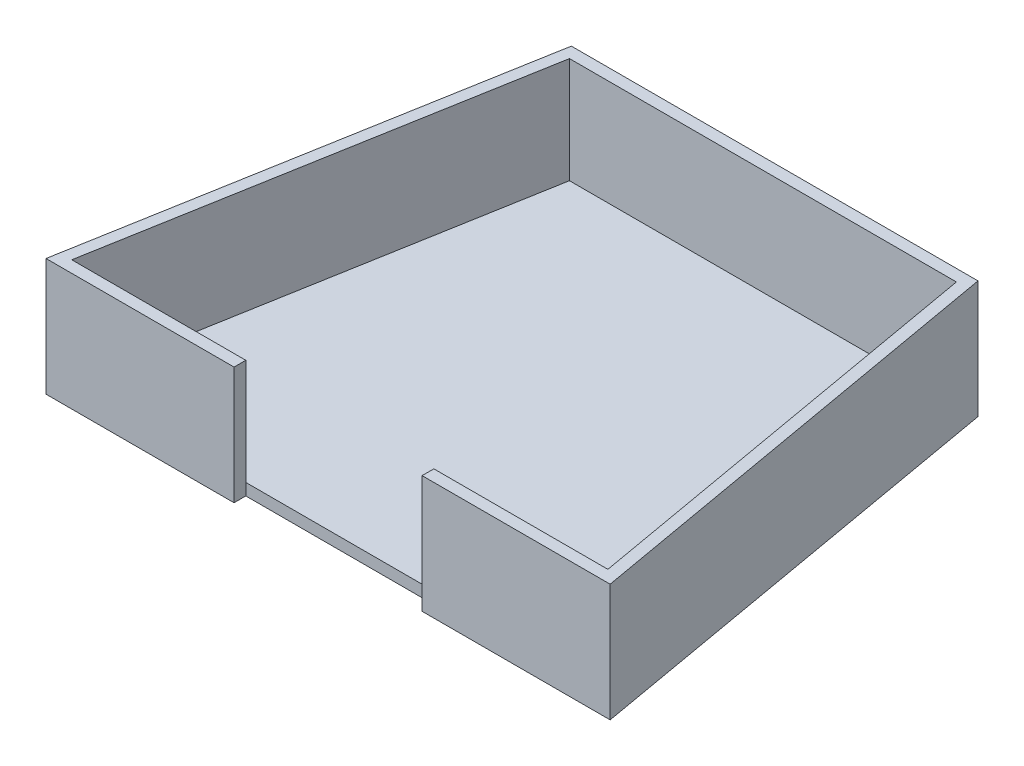
from build123d import *

# Parameters (mm, degrees)
BOSS_EXTRUDE1_DEPTH = 50
SHELL2_T            = -5
SKETCH3_W           = 80
SKETCH3_H           = 50
CUT_EXTRUDE1_DEPTH  = 5


with BuildPart() as part:
    # Sketch1 → Boss-Extrude1 (new body)
    with BuildSketch(Plane(origin=(0, 0, 0), x_dir=(1, 0, 0), z_dir=(0, 1, 0))):
        Polygon((0, 0), (33.502126335, 190), (206.497873665, 190), (240, 0), align=None)
    extrude(amount=BOSS_EXTRUDE1_DEPTH)

    # Shell2
    shell2_openings = [part.faces().sort_by_distance(p)[0] for p in [
        (120, 50, -95),
    ]]
    offset(amount=SHELL2_T, openings=shell2_openings, kind=Kind.INTERSECTION)

    # Sketch3 → Cut-Extrude1 (cut)
    with BuildSketch(Plane.XY):
        with Locations((120, 25)):
            Rectangle(SKETCH3_W, SKETCH3_H)
    extrude(amount=-CUT_EXTRUDE1_DEPTH, mode=Mode.SUBTRACT)


solid = part.part
